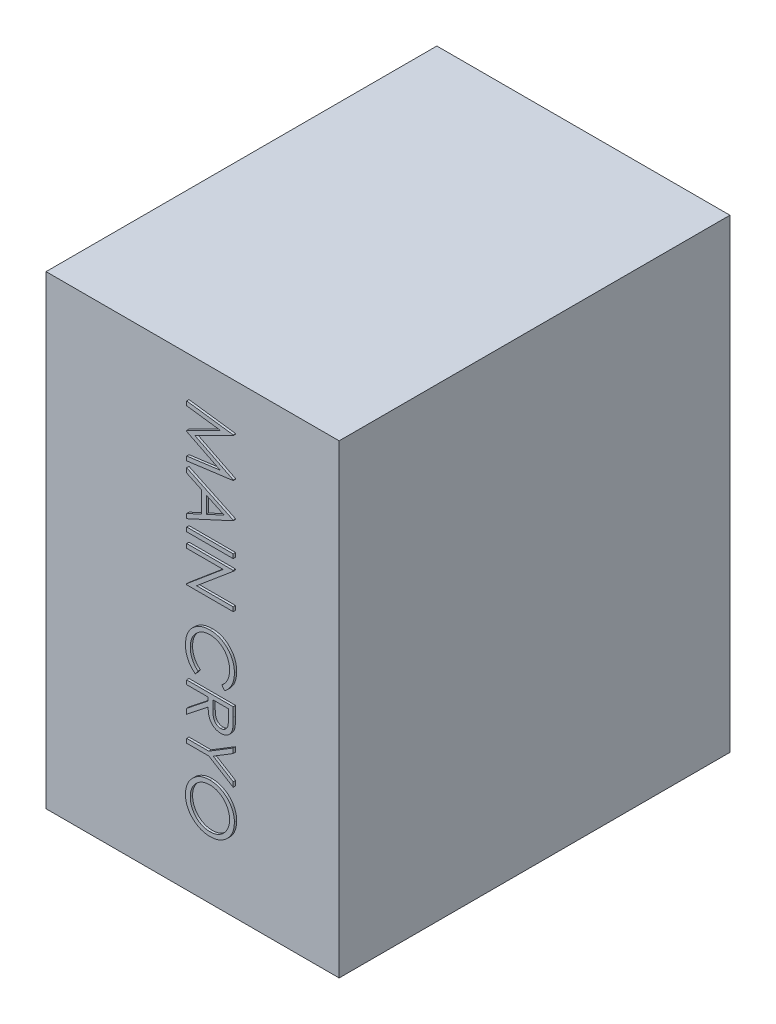
from build123d import *

# Parameters (mm, degrees)
SKETCH1_W           = 630
SKETCH1_H           = 1000
BOSS_EXTRUDE1_DEPTH = 840
SKETCH2_W           = 100
SKETCH2_H           = 8.974358974
BOSS_EXTRUDE2_DEPTH = 5


with BuildPart() as part:
    # Sketch1 → Boss-Extrude1 (new body)
    with BuildSketch(Plane.XY):
        with Locations((-315, -500)):
            Rectangle(SKETCH1_W, SKETCH1_H)
    extrude(amount=BOSS_EXTRUDE1_DEPTH)

    # Sketch2 → Boss-Extrude2 (add)
    with BuildSketch(Plane.XY.offset(840)):
        Polygon((-322.759430127, -84.615384615), (-222.759430127, -97.81650641), (-222.759430127, -99.098557692), (-304.810712179, -140.384615385), (-222.759430127, -181.570512821), (-222.759430127, -182.872596154), (-322.759430127, -196.153846154), (-322.759430127, -187.139423077), (-250.804301922, -177.564102564), (-322.759430127, -141.466346154), (-322.759430127, -139.443108974), (-250.644045512, -103.205128205), (-322.759430127, -93.649839744), align=None)
        Polygon((-222.759430127, -257.692307692), (-322.759430127, -303.846153846), (-322.759430127, -294.090544872), (-290.708148076, -279.306891026), (-290.708148076, -233.974358974), (-322.759430127, -218.770032051), (-322.759430127, -208.974358974), (-222.759430127, -256.41025641), align=None)
        Polygon((-242.250616025, -256.951121795), (-280.45173782, -238.842147436), (-280.45173782, -274.579326923), align=None, mode=Mode.SUBTRACT)
        with Locations((-272.759430127, -323.717948718)):
            Rectangle(SKETCH2_W, SKETCH2_H)
        Polygon((-322.759430127, -350), (-222.759430127, -350), (-222.759430127, -351.883012821), (-301.465359615, -417.948717949), (-222.759430127, -417.948717949), (-222.759430127, -426.923076923), (-322.759430127, -426.923076923), (-322.759430127, -424.879807692), (-244.233789102, -358.974358974), (-322.759430127, -358.974358974), align=None)
        with BuildLine():
            Line((-241.108789102, -583.333333333), (-247.118404486, -575.480769231))
            add(Edge.make_bspline(
                [(-247.118404486, -575.480769231), (-246.450805348, -574.920600992), (-245.124607756, -573.807816797), (-243.262335057, -572.017553868), (-241.517613302, -570.151792642), (-239.882131027, -568.211246322), (-238.413080577, -566.160985765), (-237.033906208, -564.050677232), (-235.797685123, -561.845018797), (-234.298742663, -558.794969236), (-232.734566806, -554.805030714), (-231.423045911, -549.782321026), (-230.588155177, -544.539146783), (-230.497731136, -540.962072508), (-230.45173782, -539.142628205)],
                knots=[0, 0, 0, 0, 0.002613856, 0.005192473, 0.007743552, 0.010275052, 0.012799409, 0.015305337, 0.017834775, 0.020379083, 0.025497771, 0.030657998, 0.035927608, 0.041382546, 0.041382546, 0.041382546, 0.041382546], degree=3))
            add(Edge.make_bspline(
                [(-230.45173782, -539.142628205), (-230.463331685, -538.140260408), (-230.486411813, -536.144827733), (-230.788761097, -533.183262962), (-231.218610706, -530.271390592), (-231.840907263, -527.420038845), (-232.651080922, -524.634869209), (-233.601198369, -521.894674925), (-234.78352311, -519.231728168), (-236.089242939, -516.61398106), (-237.564466379, -514.106119393), (-239.173045352, -511.732748614), (-240.899191888, -509.504711533), (-242.738450292, -507.415834201), (-244.713678842, -505.489025675), (-246.801641315, -503.693405971), (-249.027468934, -502.061336391), (-251.349418176, -500.552711667), (-253.770901854, -499.210305486), (-256.276686818, -498.051072751), (-258.857192544, -497.057513914), (-261.517705365, -496.264046742), (-264.247755515, -495.638189615), (-267.053136777, -495.20581907), (-269.928403756, -494.906189695), (-271.877238672, -494.88332188), (-272.859590384, -494.871794872)],
                knots=[0, 0, 0, 0, 0.003005876, 0.005983854, 0.008921744, 0.011833291, 0.014730746, 0.017619809, 0.02052639, 0.023464827, 0.026391975, 0.029247789, 0.032060635, 0.034842134, 0.037590251, 0.040332301, 0.043096797, 0.045863904, 0.048634562, 0.051394991, 0.054140551, 0.056922699, 0.059716937, 0.062536053, 0.065434269, 0.06838007, 0.06838007, 0.06838007, 0.06838007], degree=3))
            add(Edge.make_bspline(
                [(-272.859590384, -494.871794872), (-274.337628096, -494.907846844), (-277.239559092, -494.978630109), (-281.490147964, -495.608582511), (-285.562167215, -496.565870834), (-289.43016271, -498.000601604), (-293.141830083, -499.769717334), (-296.634368751, -502.005163377), (-299.960556309, -504.594207302), (-303.041783387, -507.573476429), (-305.856461253, -510.842214029), (-308.335049296, -514.349297217), (-310.401188795, -518.085991154), (-312.120501553, -522.011037731), (-313.442122343, -526.154640985), (-314.372525872, -530.509349626), (-314.979445316, -535.065692347), (-315.037550689, -538.179103773), (-315.067122435, -539.763621795)],
                knots=[0, 0, 0, 0, 0.004431613, 0.008700885, 0.012864709, 0.016958508, 0.021052943, 0.025176628, 0.029372183, 0.03367912, 0.038011651, 0.042296543, 0.046538138, 0.050799366, 0.055132591, 0.059560761, 0.064144995, 0.068896013, 0.068896013, 0.068896013, 0.068896013], degree=3))
            add(Edge.make_bspline(
                [(-315.067122435, -539.763621795), (-315.018871585, -541.509412909), (-314.92390237, -544.94554745), (-314.119352395, -549.984633916), (-312.814840457, -554.808512934), (-310.989185533, -559.417443978), (-308.615891593, -563.79843387), (-305.738809381, -567.95833845), (-302.330571303, -571.900669036), (-299.728196209, -574.2712771), (-298.400455768, -575.480769231)],
                knots=[0, 0, 0, 0, 0.005234847, 0.010303431, 0.015264994, 0.020201259, 0.0251398, 0.030179682, 0.035348806, 0.040733293, 0.040733293, 0.040733293, 0.040733293], degree=3))
            Line((-298.400455768, -575.480769231), (-304.349974999, -583.333333333))
            add(Edge.make_bspline(
                [(-304.349974999, -583.333333333), (-305.165360734, -582.701388176), (-306.792226551, -581.440524842), (-309.0856833, -579.398854772), (-311.243018678, -577.248121323), (-313.246377687, -574.97207097), (-315.137582526, -572.597925291), (-316.853232061, -570.083864897), (-318.445587722, -567.473312496), (-319.884343, -564.751069064), (-321.174344993, -561.926072085), (-322.263400342, -559.001261486), (-323.215031586, -556.001416427), (-323.992752122, -552.925026167), (-324.600744073, -549.761813335), (-325.006952771, -546.522630987), (-325.285311466, -543.200641557), (-325.310677991, -540.959457138), (-325.323532691, -539.823717949)],
                knots=[0, 0, 0, 0, 0.003094093, 0.006173365, 0.009204632, 0.012227349, 0.015265161, 0.018304559, 0.021351868, 0.024434462, 0.027536326, 0.030661647, 0.033791395, 0.036973718, 0.040175652, 0.043447997, 0.046763528, 0.050169919, 0.050169919, 0.050169919, 0.050169919], degree=3))
            add(Edge.make_bspline(
                [(-325.323532691, -539.823717949), (-325.31604719, -538.748184604), (-325.301245537, -536.621450601), (-325.061469326, -533.48148627), (-324.734333985, -530.424641104), (-324.241758812, -527.459651793), (-323.660491953, -524.570338221), (-322.881313193, -521.78289295), (-322.008479861, -519.069886939), (-320.982623097, -516.442220062), (-319.825017882, -513.897657211), (-318.516687628, -511.444405458), (-317.068634352, -509.083593103), (-315.512776911, -506.79200965), (-313.799139715, -504.60350726), (-311.951521586, -502.499120821), (-309.97614985, -500.467050072), (-308.551725469, -499.2098305), (-307.835551922, -498.577724359)],
                knots=[0, 0, 0, 0, 0.00322572, 0.006378462, 0.009442318, 0.01244579, 0.015392341, 0.018278973, 0.021123312, 0.023939366, 0.026736187, 0.029505324, 0.032274388, 0.035041423, 0.037810342, 0.040606877, 0.043439979, 0.046304772, 0.046304772, 0.046304772, 0.046304772], degree=3))
            add(Edge.make_bspline(
                [(-307.835551922, -498.577724359), (-306.591517953, -497.565277402), (-304.118469084, -495.552606635), (-300.110298191, -492.977587105), (-295.925492223, -490.773371242), (-291.542065687, -488.991202077), (-286.969854623, -487.59798113), (-282.206554211, -486.632804128), (-277.256613005, -486.005615428), (-273.889847615, -485.933892892), (-272.17850064, -485.897435897)],
                knots=[0, 0, 0, 0, 0.004808736, 0.009559416, 0.014263537, 0.018980436, 0.023733143, 0.028581148, 0.033545542, 0.038677658, 0.038677658, 0.038677658, 0.038677658], degree=3))
            add(Edge.make_bspline(
                [(-272.17850064, -485.897435897), (-270.379848651, -485.942068741), (-266.841113152, -486.029881074), (-261.646497537, -486.769781511), (-256.676849896, -487.974482362), (-251.913048206, -489.633363461), (-247.382349135, -491.821871165), (-243.065617625, -494.47123673), (-238.966378411, -497.607338057), (-235.137040652, -501.190788708), (-231.63600957, -505.121491073), (-228.555807932, -509.330545902), (-225.992456762, -513.810044376), (-223.849707539, -518.510550594), (-222.202723347, -523.467285393), (-221.049775027, -528.669667082), (-220.332143168, -534.107921868), (-220.241422938, -537.818276876), (-220.195327563, -539.703525641)],
                knots=[0, 0, 0, 0, 0.005393981, 0.010612321, 0.015704128, 0.020715545, 0.025715097, 0.030768934, 0.035885309, 0.041171987, 0.04647878, 0.051655622, 0.056788989, 0.061935004, 0.06712945, 0.072426707, 0.077900481, 0.083554631, 0.083554631, 0.083554631, 0.083554631], degree=3))
            add(Edge.make_bspline(
                [(-220.195327563, -539.703525641), (-220.209092646, -540.852512805), (-220.236339242, -543.126817184), (-220.502378233, -546.491146049), (-220.945075535, -549.766761076), (-221.55160077, -552.961583887), (-222.29499739, -556.087199562), (-223.268161015, -559.111541627), (-224.398242555, -562.051078757), (-225.666596994, -564.908012504), (-227.116616726, -567.651260286), (-228.691490153, -570.280322875), (-230.427570617, -572.763485441), (-232.267463247, -575.147456436), (-234.279992109, -577.378565128), (-236.399617638, -579.52053143), (-238.689236549, -581.499363757), (-240.300795207, -582.720891079), (-241.108789102, -583.333333333)],
                knots=[0, 0, 0, 0, 0.003446444, 0.00682189, 0.010116721, 0.013358015, 0.016574392, 0.019748382, 0.022880821, 0.026019211, 0.029119523, 0.032183968, 0.035206884, 0.038204204, 0.041211948, 0.044214885, 0.04723946, 0.050280705, 0.050280705, 0.050280705, 0.050280705], degree=3))
        make_face()
        with BuildLine():
            Line((-222.759430127, -603.846153846), (-222.759430127, -623.858173077))
            add(Edge.make_bspline(
                [(-222.759430127, -623.858173077), (-222.763875441, -625.193633892), (-222.772410937, -627.757866589), (-222.820004162, -631.431388599), (-222.956414326, -634.769305656), (-223.073802425, -637.769872494), (-223.287857891, -640.433034065), (-223.492447809, -642.766956658), (-223.760266688, -644.760890872), (-224.008993059, -645.967915195), (-224.121609615, -646.514423077)],
                knots=[0, 0, 0, 0, 0.00400646, 0.007692848, 0.01102034, 0.014028417, 0.0167002, 0.019034343, 0.021057084, 0.02273069, 0.02273069, 0.02273069, 0.02273069], degree=3))
            add(Edge.make_bspline(
                [(-224.121609615, -646.514423077), (-224.302353833, -647.246053796), (-224.659986504, -648.693707566), (-225.416272604, -650.777808208), (-226.290021426, -652.764621504), (-227.324237371, -654.646691526), (-228.500881484, -656.424192866), (-229.826828467, -658.094464122), (-231.308830866, -659.647955878), (-232.909044573, -661.096621494), (-234.641431941, -662.409790254), (-236.480756774, -663.546166), (-238.415515177, -664.519238848), (-240.45244469, -665.296072165), (-242.574326425, -665.921010752), (-244.799688406, -666.361800806), (-247.118582314, -666.626109295), (-248.700235621, -666.653020994), (-249.502218589, -666.666666667)],
                knots=[0, 0, 0, 0, 0.002259452, 0.004470704, 0.006640925, 0.008765645, 0.01090467, 0.013028918, 0.015154393, 0.017338713, 0.019498183, 0.021666185, 0.02381625, 0.025985084, 0.028197424, 0.030444588, 0.032782853, 0.035188034, 0.035188034, 0.035188034, 0.035188034], degree=3))
            add(Edge.make_bspline(
                [(-249.502218589, -666.666666667), (-250.834651682, -666.624696381), (-253.434573757, -666.542801484), (-257.20772038, -665.779211879), (-260.727493402, -664.52850981), (-263.988994518, -662.804782284), (-266.930366525, -660.610698745), (-269.505131437, -657.973909256), (-271.679637716, -654.907879718), (-273.171540678, -652.040206729), (-274.131494989, -649.505852902), (-274.810313055, -647.413290904), (-275.325940962, -645.128926217), (-275.794574683, -642.685531523), (-276.152179862, -640.064233796), (-276.406147503, -637.270311687), (-276.569450629, -634.296777432), (-276.593309915, -632.258498528), (-276.605583974, -631.209935897)],
                knots=[0, 0, 0, 0, 0.003993619, 0.007792586, 0.011492826, 0.015166947, 0.018816795, 0.022457397, 0.026176297, 0.030055746, 0.032116712, 0.03430241, 0.03664924, 0.039136201, 0.041765212, 0.044581764, 0.047550836, 0.050696442, 0.050696442, 0.050696442, 0.050696442], degree=3))
            Line((-276.605583974, -631.209935897), (-322.759430127, -667.948717949))
            Line((-322.759430127, -667.948717949), (-322.759430127, -656.850961538))
            Line((-322.759430127, -656.850961538), (-276.605583974, -620.112179487))
            Line((-276.605583974, -620.112179487), (-276.605583974, -612.820512821))
            Line((-276.605583974, -612.820512821), (-322.759430127, -612.820512821))
            Line((-322.759430127, -612.820512821), (-322.759430127, -603.846153846))
            Line((-322.759430127, -603.846153846), (-222.759430127, -603.846153846))
        make_face()
        with BuildLine():
            Line((-233.015840384, -612.820512821), (-266.349173717, -612.820512821))
            Line((-266.349173717, -612.820512821), (-266.489398076, -631.129807692))
            add(Edge.make_bspline(
                [(-266.489398076, -631.129807692), (-266.489776263, -631.984665944), (-266.490509298, -633.641624712), (-266.376401443, -636.038786611), (-266.246592224, -638.270789639), (-266.048039915, -640.32909739), (-265.792150771, -642.214626318), (-265.472070008, -643.926443979), (-265.099139264, -645.467312099), (-264.522011752, -647.264493569), (-263.607136352, -649.2707083), (-262.278331962, -651.453738104), (-260.596171243, -653.306457342), (-258.703217946, -654.903860421), (-256.579149751, -656.134267636), (-254.318246041, -657.029788217), (-251.940025941, -657.591777284), (-250.306544686, -657.658589842), (-249.482186538, -657.692307692)],
                knots=[0, 0, 0, 0, 0.002564181, 0.004970113, 0.007198088, 0.00927109, 0.011172025, 0.012904653, 0.014493385, 0.015925082, 0.018561105, 0.021090067, 0.023558809, 0.026033882, 0.028493831, 0.030885712, 0.033310583, 0.035781112, 0.035781112, 0.035781112, 0.035781112], degree=3))
            add(Edge.make_bspline(
                [(-249.482186538, -657.692307692), (-248.677775704, -657.658486197), (-247.083726955, -657.591464333), (-244.756485914, -657.028699342), (-242.544289871, -656.119916162), (-240.489304758, -654.845591819), (-238.608390704, -653.305766301), (-237.021278787, -651.476994533), (-235.69216506, -649.451375704), (-234.849018101, -647.556797926), (-234.331059541, -645.864564894), (-233.96702628, -644.395076137), (-233.672087748, -642.728368422), (-233.442778613, -640.868436089), (-233.236426595, -638.818644062), (-233.102633412, -636.573379616), (-233.02176879, -634.135235537), (-233.017862508, -632.445316045), (-233.015840384, -631.570512821)],
                knots=[0, 0, 0, 0, 0.002410597, 0.004776925, 0.007139178, 0.009557836, 0.0120047, 0.014403617, 0.016792811, 0.019249822, 0.020593016, 0.022099154, 0.023788748, 0.025667174, 0.027720239, 0.029968207, 0.03241343, 0.035037705, 0.035037705, 0.035037705, 0.035037705], degree=3))
            Line((-233.015840384, -631.570512821), (-233.015840384, -612.820512821))
        make_face(mode=Mode.SUBTRACT)
        Polygon((-222.759430127, -680.769230769), (-222.759430127, -691.045673077), (-265.728180127, -717.327724359), (-222.759430127, -743.569711538), (-222.759430127, -753.846153846), (-275.223372435, -721.794871795), (-322.759430127, -721.794871795), (-322.759430127, -712.820512821), (-275.223372435, -712.820512821), align=None)
        with BuildLine():
            add(Edge.make_bspline(
                [(-220.195327563, -817.307692308), (-220.242227401, -819.159352104), (-220.334342552, -822.796164714), (-221.039453723, -828.141167086), (-222.259344258, -833.2438647), (-223.883919734, -838.145939414), (-226.05148768, -842.788334574), (-228.669939572, -847.207568182), (-231.776515965, -851.39114538), (-235.31908994, -855.300718637), (-239.187605162, -858.865215202), (-243.327909482, -861.979491297), (-247.683307895, -864.612588206), (-252.26895604, -866.770753119), (-257.064670847, -868.465384904), (-262.097719871, -869.634395239), (-267.335032693, -870.381228273), (-270.907231743, -870.468532243), (-272.719366025, -870.512820513)],
                knots=[0, 0, 0, 0, 0.005554083, 0.010908677, 0.01613685, 0.021274319, 0.026374041, 0.031475768, 0.036660162, 0.041978775, 0.047281256, 0.052417475, 0.057495116, 0.062522243, 0.067596999, 0.072723091, 0.078000957, 0.083434962, 0.083434962, 0.083434962, 0.083434962], degree=3))
            add(Edge.make_bspline(
                [(-272.719366025, -870.512820513), (-274.518151758, -870.468538808), (-278.063766828, -870.381254438), (-283.267842992, -869.633545237), (-288.270515976, -868.461054805), (-293.062948715, -866.786472962), (-297.651998721, -864.638675886), (-302.015402806, -861.987783079), (-306.184375007, -858.894125504), (-310.071670107, -855.341949305), (-313.64316908, -851.474356624), (-316.76228704, -847.322376947), (-319.427803636, -842.971264888), (-321.571165874, -838.388388858), (-323.277791006, -833.624840322), (-324.442462741, -828.636961541), (-325.193436412, -823.447008882), (-325.279691405, -819.907844393), (-325.323532691, -818.108974359)],
                knots=[0, 0, 0, 0, 0.005393981, 0.010632161, 0.015738763, 0.020787992, 0.025833246, 0.030910887, 0.036079195, 0.041382962, 0.046685443, 0.051849712, 0.056937735, 0.061964862, 0.067001837, 0.072088953, 0.077307293, 0.082701274, 0.082701274, 0.082701274, 0.082701274], degree=3))
            add(Edge.make_bspline(
                [(-325.323532691, -818.108974359), (-325.279270436, -816.296847416), (-325.192017749, -812.724662833), (-324.443892427, -807.480798345), (-323.274453269, -802.444105061), (-321.601612358, -797.630090889), (-319.447800834, -793.037176069), (-316.801086323, -788.665804805), (-313.682296774, -784.510724204), (-310.134849845, -780.614217029), (-306.265398439, -777.053336211), (-302.140709918, -773.92133591), (-297.800012433, -771.289880268), (-293.261199163, -769.135159524), (-288.536002154, -767.430857457), (-283.594698153, -766.267754946), (-278.464975995, -765.515328391), (-274.972324778, -765.428614478), (-273.200135256, -765.384615385)],
                knots=[0, 0, 0, 0, 0.005434005, 0.010711871, 0.015857458, 0.020925606, 0.02597086, 0.031048501, 0.036228791, 0.041532558, 0.046835039, 0.051983315, 0.057043817, 0.062034733, 0.067033965, 0.072082121, 0.077240948, 0.082554881, 0.082554881, 0.082554881, 0.082554881], degree=3))
            add(Edge.make_bspline(
                [(-273.200135256, -765.384615385), (-272.010624987, -765.399876678), (-269.646610653, -765.430206736), (-266.136216353, -765.795889755), (-262.681897767, -766.32545167), (-259.295266642, -767.088366818), (-255.975769949, -768.07246264), (-252.730196245, -769.285193795), (-249.531811539, -770.674984166), (-246.441486763, -772.329721577), (-243.454371435, -774.135089615), (-240.607816946, -776.103662068), (-237.952670445, -778.249164739), (-235.446267988, -780.540949628), (-233.131388163, -783.010740174), (-230.957561258, -785.621366104), (-228.947289929, -788.386487399), (-227.142795409, -791.310477165), (-225.48534527, -794.318787177), (-224.101510801, -797.433242869), (-222.878386711, -800.588132357), (-221.906365765, -803.811245144), (-221.132825703, -807.095125641), (-220.607224781, -810.443879054), (-220.240729223, -813.854056212), (-220.210526563, -816.151527199), (-220.195327563, -817.307692308)],
                knots=[0, 0, 0, 0, 0.003567112, 0.007089222, 0.010576929, 0.014046871, 0.017494829, 0.020955449, 0.024435553, 0.027948252, 0.031462778, 0.034902521, 0.038321963, 0.04169616, 0.045082999, 0.048468593, 0.051882516, 0.055328785, 0.058770861, 0.062177782, 0.065544657, 0.068915879, 0.07226866, 0.075657454, 0.079079887, 0.082546879, 0.082546879, 0.082546879, 0.082546879], degree=3))
        make_face()
        with BuildLine():
            add(Edge.make_bspline(
                [(-230.45173782, -817.748397436), (-230.463300606, -816.79940574), (-230.486315636, -814.910494773), (-230.789703219, -812.102397192), (-231.221679179, -809.331078498), (-231.839437912, -806.596689479), (-232.673389792, -803.913944941), (-233.656024183, -801.256054044), (-234.811944636, -798.635779042), (-236.159776664, -796.082412744), (-237.632136781, -793.600223105), (-239.248103036, -791.241936425), (-240.999839706, -789.031078214), (-242.864207511, -786.960566292), (-244.860175675, -785.036434098), (-246.955888393, -783.219678165), (-249.211675895, -781.583417931), (-251.56625377, -780.083826371), (-254.016586046, -778.741889053), (-256.536867455, -777.548592943), (-259.147658605, -776.572478476), (-261.820634509, -775.776410563), (-264.551561935, -775.116415972), (-267.361157614, -774.698303854), (-270.235303673, -774.391665013), (-272.17764236, -774.369955143), (-273.160071153, -774.358974359)],
                knots=[0, 0, 0, 0, 0.00284568, 0.005664154, 0.008463486, 0.011257723, 0.014064857, 0.016885395, 0.019755297, 0.022649425, 0.025542098, 0.028409202, 0.031218621, 0.033998533, 0.036760996, 0.039531291, 0.042311925, 0.045112761, 0.047900961, 0.050688009, 0.053471022, 0.05625317, 0.059051928, 0.061890831, 0.06476911, 0.067714912, 0.067714912, 0.067714912, 0.067714912], degree=3))
            add(Edge.make_bspline(
                [(-273.160071153, -774.358974359), (-274.604706033, -774.395398986), (-277.446749755, -774.467057497), (-281.611553866, -775.094416643), (-285.614076333, -776.06075877), (-289.432416598, -777.485254954), (-293.099396108, -779.266701087), (-296.582484813, -781.467469381), (-299.882624081, -784.074871825), (-302.976774623, -787.036686871), (-305.800940458, -790.274478488), (-308.279894991, -793.712556486), (-310.3773307, -797.314088129), (-312.086047054, -801.088465349), (-313.440039562, -805.015537893), (-314.368000452, -809.12061078), (-314.978727748, -813.376338196), (-315.037377917, -816.277214058), (-315.067122435, -817.748397436)],
                knots=[0, 0, 0, 0, 0.004331558, 0.008521514, 0.012607512, 0.016663693, 0.0207221, 0.024818152, 0.028997945, 0.033319346, 0.037649838, 0.041869427, 0.046016449, 0.050131268, 0.054280611, 0.058454687, 0.062741031, 0.067151769, 0.067151769, 0.067151769, 0.067151769], degree=3))
            add(Edge.make_bspline(
                [(-315.067122435, -817.748397436), (-315.053536636, -818.737240367), (-315.026591916, -820.698412891), (-314.755200562, -823.615427402), (-314.320006498, -826.479892146), (-313.693408197, -829.287780126), (-312.909232402, -832.035938789), (-311.977470944, -834.735711387), (-310.815572924, -837.358816868), (-309.529753561, -839.936548341), (-308.074454619, -842.404399052), (-306.48107634, -844.745789717), (-304.760667557, -846.947146332), (-302.912489649, -849.013236905), (-300.952474413, -850.950701185), (-298.830226622, -852.706928889), (-296.607725667, -854.362791255), (-294.247655735, -855.856378285), (-291.792159908, -857.195647599), (-289.262331998, -858.360225314), (-286.666866153, -859.348829295), (-284.001363399, -860.146747913), (-281.271061342, -860.77205726), (-278.472256962, -861.20290928), (-275.610562043, -861.504294007), (-273.675023222, -861.527010394), (-272.699333974, -861.538461538)],
                knots=[0, 0, 0, 0, 0.002965826, 0.005882124, 0.00878041, 0.011652827, 0.014506252, 0.017350874, 0.020212724, 0.023106368, 0.025988826, 0.028800244, 0.031597281, 0.034363808, 0.037111925, 0.039856316, 0.042620812, 0.045421648, 0.048227423, 0.051006035, 0.053770313, 0.056552461, 0.059346699, 0.062165814, 0.065044093, 0.06796987, 0.06796987, 0.06796987, 0.06796987], degree=3))
            add(Edge.make_bspline(
                [(-272.699333974, -861.538461538), (-271.730319566, -861.527001168), (-269.808100989, -861.504267411), (-266.966363322, -861.20305385), (-264.187700137, -860.77159984), (-261.483020051, -860.149808182), (-258.851633621, -859.348375218), (-256.296012258, -858.360165778), (-253.806635255, -857.194871507), (-251.389655343, -855.857493668), (-249.070377109, -854.354184427), (-246.853165342, -852.711491755), (-244.779658375, -850.901053258), (-242.798667389, -848.974595326), (-240.952440936, -846.883998899), (-239.240372869, -844.638732223), (-237.621121399, -842.266060026), (-236.160448754, -839.753836788), (-234.811254672, -837.161214215), (-233.656307253, -834.50058774), (-232.669140048, -831.797437049), (-231.842851438, -829.065602148), (-231.221073945, -826.285838356), (-230.789858205, -823.474333418), (-230.486283152, -820.626281743), (-230.463289472, -818.710736372), (-230.45173782, -817.748397436)],
                knots=[0, 0, 0, 0, 0.002905752, 0.005764095, 0.008563427, 0.011338137, 0.014081943, 0.016808805, 0.019551075, 0.022321733, 0.02508884, 0.027837249, 0.030592366, 0.033340483, 0.036121983, 0.03895069, 0.041806504, 0.044733653, 0.047663336, 0.050569917, 0.053428049, 0.056292702, 0.059126016, 0.061964919, 0.064823262, 0.06770899, 0.06770899, 0.06770899, 0.06770899], degree=3))
        make_face(mode=Mode.SUBTRACT)
    extrude(amount=BOSS_EXTRUDE2_DEPTH)


solid = part.part
